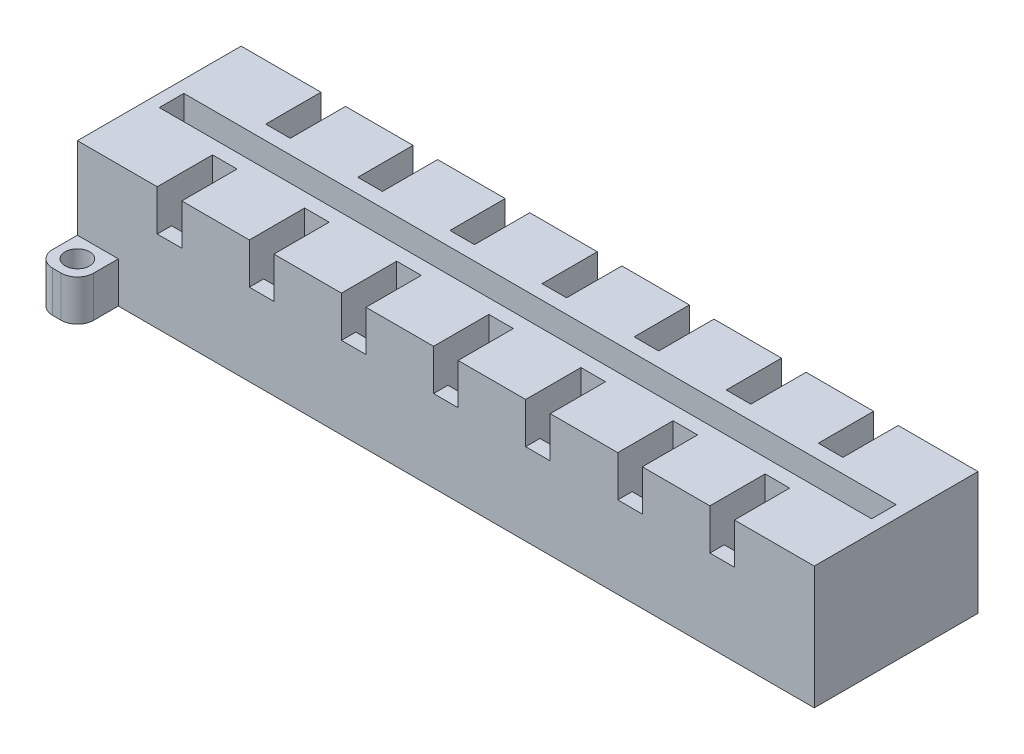
from build123d import *

# Parameters (mm, degrees)
SKETCH1_W           = 90
SKETCH1_H           = 20
BOSS_EXTRUDE1_DEPTH = 20
SKETCH2_W           = 90
SKETCH2_H           = 3
CUT_EXTRUDE1_DEPTH  = 10
SKETCH3_W           = 3
SKETCH3_H           = 5
CUT_EXTRUDE2_DEPTH  = 10
SKETCH4_W           = 3
SKETCH4_H           = 1.75
SKETCH4_W_2         = 2.997618753
SKETCH4_W_3         = 3.002941468
CUT_EXTRUDE3_DEPTH  = 5
SKETCH5_W           = 1.5
SKETCH5_H           = 3
BOSS_EXTRUDE2_DEPTH = 10
SKETCH6_W           = 90
SKETCH6_H           = 5
CUT_EXTRUDE4_DEPTH  = 56
SKETCH7_W           = 5
SKETCH7_H           = 5
BOSS_EXTRUDE3_DEPTH = 5
SKETCH8_R           = 1.5
CUT_EXTRUDE5_DEPTH  = 5
FILLET3_R           = 1.98


with BuildPart() as part:
    # Sketch1 → Boss-Extrude1 (new body)
    with BuildSketch(Plane.XY):
        with Locations((45, -10)):
            Rectangle(SKETCH1_W, SKETCH1_H)
    extrude(amount=BOSS_EXTRUDE1_DEPTH)

    # Sketch2 → Cut-Extrude1 (cut)
    with BuildSketch(Plane(origin=(0, 0, 0), x_dir=(1, 0, 0), z_dir=(0, 1, 0))):
        with Locations((45, -10)):
            Rectangle(SKETCH2_W, SKETCH2_H)
    extrude(amount=-CUT_EXTRUDE1_DEPTH, mode=Mode.SUBTRACT)

    # Sketch3 → Cut-Extrude2 (cut)
    with BuildSketch(Plane(origin=(0, 0, 0), x_dir=(1, 0, 0), z_dir=(0, 1, 0))):
        with Locations((11.25, -15.75)):
            Rectangle(SKETCH3_W, SKETCH3_H)
        with Locations((22.5, -15.75)):
            Rectangle(SKETCH3_W, SKETCH3_H)
        with Locations((33.75, -15.75)):
            Rectangle(SKETCH3_W, SKETCH3_H)
        with Locations((45, -15.75)):
            Rectangle(SKETCH3_W, SKETCH3_H)
        with Locations((56.25, -15.75)):
            Rectangle(SKETCH3_W, SKETCH3_H)
        with Locations((67.5, -15.75)):
            Rectangle(SKETCH3_W, SKETCH3_H)
        with Locations((78.75, -15.75)):
            Rectangle(SKETCH3_W, SKETCH3_H)
        with Locations((11.25, -4.25)):
            Rectangle(SKETCH3_W, SKETCH3_H)
        with Locations((22.5, -4.25)):
            Rectangle(SKETCH3_W, SKETCH3_H)
        with Locations((33.75, -4.25)):
            Rectangle(SKETCH3_W, SKETCH3_H)
        with Locations((45, -4.25)):
            Rectangle(SKETCH3_W, SKETCH3_H)
        with Locations((56.25, -4.25)):
            Rectangle(SKETCH3_W, SKETCH3_H)
        with Locations((67.5, -4.25)):
            Rectangle(SKETCH3_W, SKETCH3_H)
        with Locations((78.75, -4.25)):
            Rectangle(SKETCH3_W, SKETCH3_H)
    extrude(amount=-CUT_EXTRUDE2_DEPTH, mode=Mode.SUBTRACT)

    # Sketch4 → Cut-Extrude3 (cut)
    with BuildSketch(Plane(origin=(0, 0, 0), x_dir=(1, 0, 0), z_dir=(0, 1, 0))):
        with Locations((56.25, -19.125)):
            Rectangle(SKETCH4_W, SKETCH4_H)
        with Locations((67.5, -19.125)):
            Rectangle(SKETCH4_W, SKETCH4_H)
        Polygon((77.25, -18.25), (77.25, -20), (80.252941468, -20), (80.252941468, -18.25), (80.25, -18.25), align=None)
        with Locations((45, -19.125)):
            Rectangle(SKETCH4_W, SKETCH4_H)
        with Locations((33.748809377, -19.125)):
            Rectangle(SKETCH4_W_2, SKETCH4_H)
        with Locations((22.5, -19.125)):
            Rectangle(SKETCH4_W, SKETCH4_H)
        with Locations((11.25, -19.125)):
            Rectangle(SKETCH4_W, SKETCH4_H)
        with Locations((22.5, -0.875)):
            Rectangle(SKETCH4_W, SKETCH4_H)
        with Locations((33.748809377, -0.875)):
            Rectangle(SKETCH4_W_2, SKETCH4_H)
        with Locations((45, -0.875)):
            Rectangle(SKETCH4_W, SKETCH4_H)
        with Locations((56.25, -0.875)):
            Rectangle(SKETCH4_W, SKETCH4_H)
        with Locations((67.5, -0.875)):
            Rectangle(SKETCH4_W, SKETCH4_H)
        with Locations((78.751470734, -0.875)):
            Rectangle(SKETCH4_W_3, SKETCH4_H)
        with Locations((11.25, -0.875)):
            Rectangle(SKETCH4_W, SKETCH4_H)
    extrude(amount=-CUT_EXTRUDE3_DEPTH, mode=Mode.SUBTRACT)

    # Sketch5 → Boss-Extrude2 (add)
    with BuildSketch(Plane(origin=(0, -10, 0), x_dir=(1, 0, 0), z_dir=(0, 1, 0))):
        with Locations((0.75, -10)):
            Rectangle(SKETCH5_W, SKETCH5_H)
        with Locations((89.25, -10)):
            Rectangle(SKETCH5_W, SKETCH5_H)
    extrude(amount=BOSS_EXTRUDE2_DEPTH)

    # Sketch6 → Cut-Extrude4 (cut)
    with BuildSketch(Plane.XY.offset(20)):
        with Locations((45, -17.5)):
            Rectangle(SKETCH6_W, SKETCH6_H)
    extrude(amount=-CUT_EXTRUDE4_DEPTH, mode=Mode.SUBTRACT)

    # Sketch7 → Boss-Extrude3 (add)
    with BuildSketch(Plane.XZ.offset(15)):
        with Locations((2.5, 22.5)):
            Rectangle(SKETCH7_W, SKETCH7_H)
        with Locations((2.5, -2.5)):
            Rectangle(SKETCH7_W, SKETCH7_H)
    extrude(amount=-BOSS_EXTRUDE3_DEPTH)

    # Sketch8 → Cut-Extrude5 (cut)
    with BuildSketch(Plane(origin=(0, -10, 0), x_dir=(1, 0, 0), z_dir=(0, 1, 0))):
        with Locations((2.5, 2.5)):
            Circle(SKETCH8_R)
        with Locations((2.5, -22.5)):
            Circle(SKETCH8_R)
    extrude(amount=-CUT_EXTRUDE5_DEPTH, mode=Mode.SUBTRACT)

    # Fillet3
    fillet3_edges = [part.edges().sort_by_distance(p)[0] for p in [
        (0, -12.5, 25),
        (5, -12.5, 25),
        (0, -12.5, -5),
        (5, -12.5, -5),
    ]]
    fillet(fillet3_edges, radius=FILLET3_R)


solid = part.part
